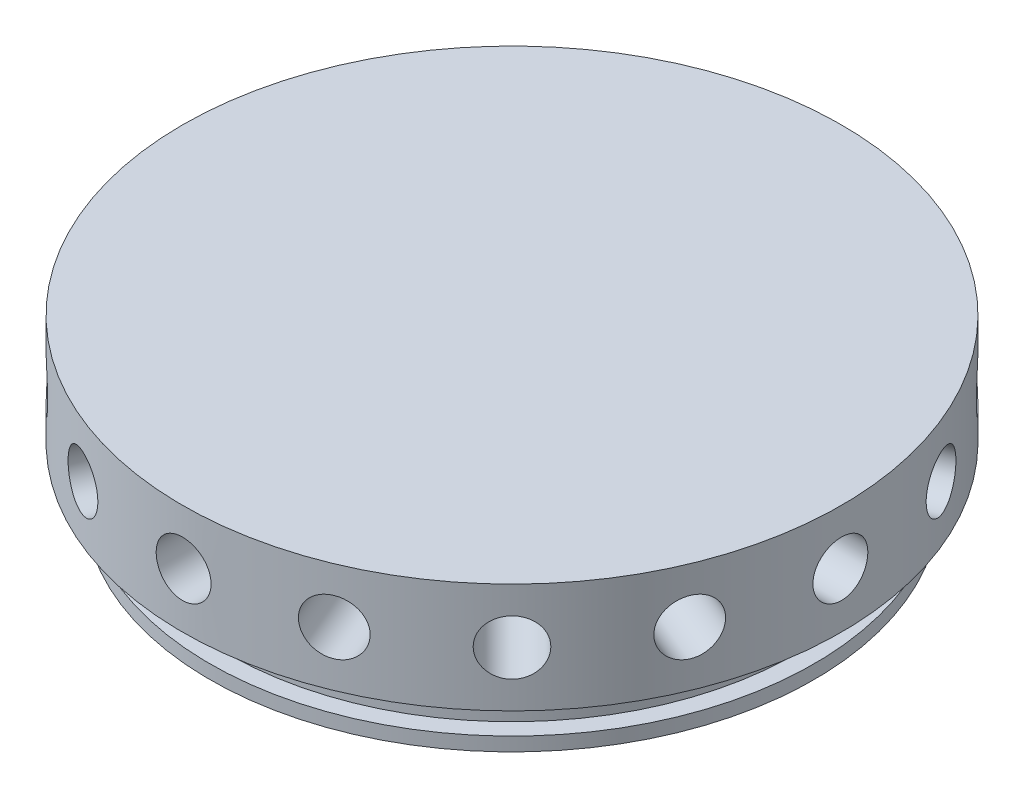
from build123d import *

# Parameters (mm, degrees)
CIRPATTERN1_COUNT = 16
CIRPATTERN2_COUNT = 8
CIRPATTERN3_COUNT = 4


with BuildPart() as part:
    # Sketch1 → Revolve1 (revolve)
    with BuildSketch(Plane.XY):
        Polygon((0, 0), (-34.925, 0), (-34.925, 1.5875), (-32.893, 1.5875), (-32.893, 4.3307), (-34.925, 4.3307), (-34.925, 6.35), (-38.1, 6.35), (-38.1, 19.05), (0, 19.05), align=None)
    revolve(axis=Axis((0, 19.05, 0), (0, -1, 0)))

    # Sketch3 → 1/4 (0.25) Diameter Hole1 (revolve, cut)
    with BuildSketch(Plane(origin=(-38.1, 12.7, 0), x_dir=(0, 0, 1), z_dir=(0, 1, 0))):
        Polygon((0, 0), (0, 14.607732465), (3.175, 12.7), (3.175, 0), align=None)
    f_1_4_0_25_diameter_hole1 = revolve(axis=Axis((-44.45, 12.7, 0), (1, 0, 0)), mode=Mode.SUBTRACT)

    # Sketch5 → 3/16 (0.1875) Diameter Hole2 (revolve, cut)
    with BuildSketch(Plane(origin=(-38.1, 12.7, 0), x_dir=(0, 0, 1), z_dir=(0, 1, 0))):
        Polygon((0, 0), (0, 25.243299349), (2.38125, 23.8125), (2.38125, 0), align=None)
    f_3_16_0_1875_diameter_hole2 = revolve(axis=Axis((-44.45, 12.7, 0), (1, 0, 0)), mode=Mode.SUBTRACT)

    # Sketch7 → 1/8 (0.125) Diameter Hole1 (revolve, cut)
    with BuildSketch(Plane(origin=(-38.1, 12.7, 0), x_dir=(0, 0, 1), z_dir=(0, 1, 0))):
        Polygon((0, 0), (0, 34.291366233), (1.5875, 33.3375), (1.5875, 0), align=None)
    f_1_8_0_125_diameter_hole1 = revolve(axis=Axis((-44.45, 12.7, 0), (1, 0, 0)), mode=Mode.SUBTRACT)

    # CirPattern1: 1/4 (0.25) Diameter Hole1 ×16 about axis
    cirpattern1_axis = Axis((0, 20.0025, 0), (0, -1, 0))
    for i in range(1, CIRPATTERN1_COUNT):
        add(f_1_4_0_25_diameter_hole1.rotate(cirpattern1_axis, i * 360 / CIRPATTERN1_COUNT), mode=Mode.SUBTRACT)

    # CirPattern2: 3/16 (0.1875) Diameter Hole2 ×8 about axis
    cirpattern2_axis = Axis((0, 20.0025, 0), (0, -1, 0))
    for i in range(1, CIRPATTERN2_COUNT):
        add(f_3_16_0_1875_diameter_hole2.rotate(cirpattern2_axis, i * 360 / CIRPATTERN2_COUNT), mode=Mode.SUBTRACT)

    # CirPattern3: 1/8 (0.125) Diameter Hole1 ×4 about axis
    cirpattern3_axis = Axis((0, 20.0025, 0), (0, -1, 0))
    for i in range(1, CIRPATTERN3_COUNT):
        add(f_1_8_0_125_diameter_hole1.rotate(cirpattern3_axis, i * 360 / CIRPATTERN3_COUNT), mode=Mode.SUBTRACT)


solid = part.part
